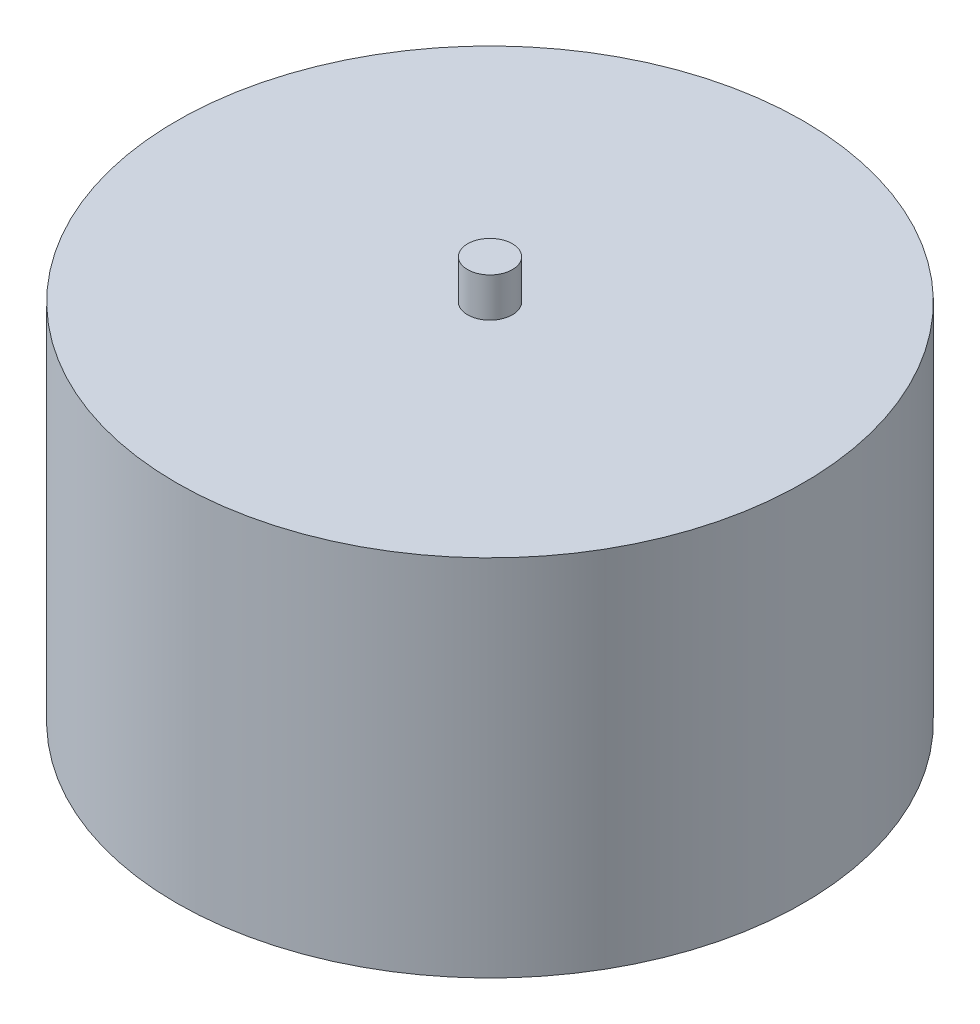
from build123d import *

# Parameters (mm, degrees)
SKETCH1_R           = 28
BOSS_EXTRUDE1_DEPTH = 32.5
SKETCH2_R           = 2
BOSS_EXTRUDE2_DEPTH = 3.5


with BuildPart() as part:
    # Sketch1 → Boss-Extrude1 (new body)
    with BuildSketch(Plane(origin=(0, 0, 0), x_dir=(1, 0, 0), z_dir=(0, 1, 0))):
        Circle(SKETCH1_R)
    extrude(amount=BOSS_EXTRUDE1_DEPTH)

    # Sketch2 → Boss-Extrude2 (add)
    with BuildSketch(Plane(origin=(0, 32.5, 0), x_dir=(1, 0, 0), z_dir=(0, 1, 0))):
        Circle(SKETCH2_R)
    extrude(amount=BOSS_EXTRUDE2_DEPTH)


solid = part.part
